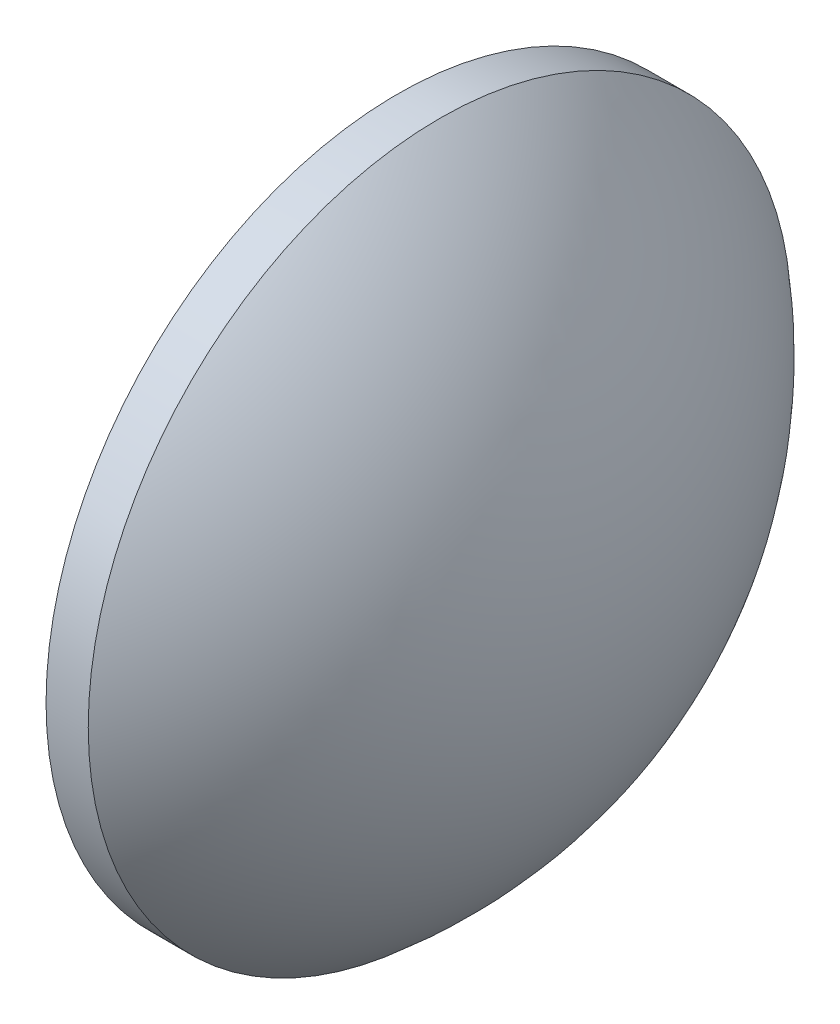
from build123d import *


with BuildPart() as part:
    # 草图1 → 旋转1 (revolve)
    with BuildSketch(Plane.XY):
        with BuildLine():
            Line((439.11042213, 106.670754482), (439.11042213, 131.670754482))
            Line((439.11042213, 131.670754482), (442.11042213, 131.670754482))
            ThreePointArc((442.11042213, 131.670754482), (450.762170474, 120.478296804), (453.84042213, 106.670754482))
            Line((453.84042213, 106.670754482), (439.11042213, 106.670754482))
        make_face()
    revolve(axis=Axis((429.688182693, 106.670754482, 0), (1, 0, 0)))


solid = part.part
